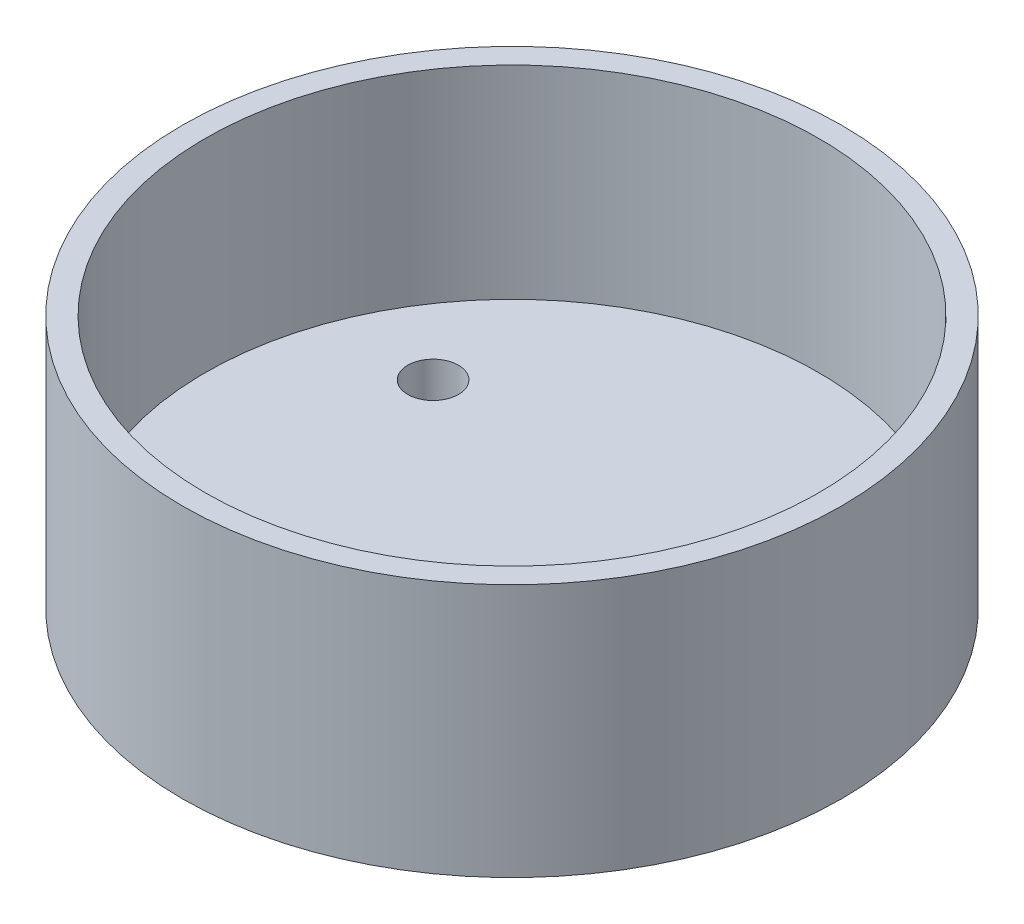
from build123d import *

# Parameters (mm, degrees)
SKETCH2_R           = 13
BOSS_EXTRUDE2_DEPTH = 10
SKETCH5_R           = 12.1
CUT_EXTRUDE2_DEPTH  = 8
SKETCH6_R           = 1
CUT_EXTRUDE3_DEPTH  = 8


with BuildPart() as part:
    # Sketch2 → Boss-Extrude2 (new body)
    with BuildSketch(Plane(origin=(0, 0, 0), x_dir=(1, 0, 0), z_dir=(0, 1, 0))):
        Circle(SKETCH2_R)
    extrude(amount=BOSS_EXTRUDE2_DEPTH)

    # Sketch5 → Cut-Extrude2 (cut)
    with BuildSketch(Plane(origin=(0, 10, 0), x_dir=(1, 0, 0), z_dir=(0, 1, 0))):
        Circle(SKETCH5_R)
    extrude(amount=-CUT_EXTRUDE2_DEPTH, mode=Mode.SUBTRACT)

    # Sketch6 → Cut-Extrude3 (cut)
    with BuildSketch(Plane(origin=(0, 2, 0), x_dir=(1, 0, 0), z_dir=(0, 1, 0))):
        with Locations((0, -8.5)):
            Circle(SKETCH6_R)
        with Locations((-7.361215932, 4.25)):
            Circle(SKETCH6_R)
        with Locations((7.361215932, 4.25)):
            Circle(SKETCH6_R)
    extrude(amount=-CUT_EXTRUDE3_DEPTH, mode=Mode.SUBTRACT)


solid = part.part
